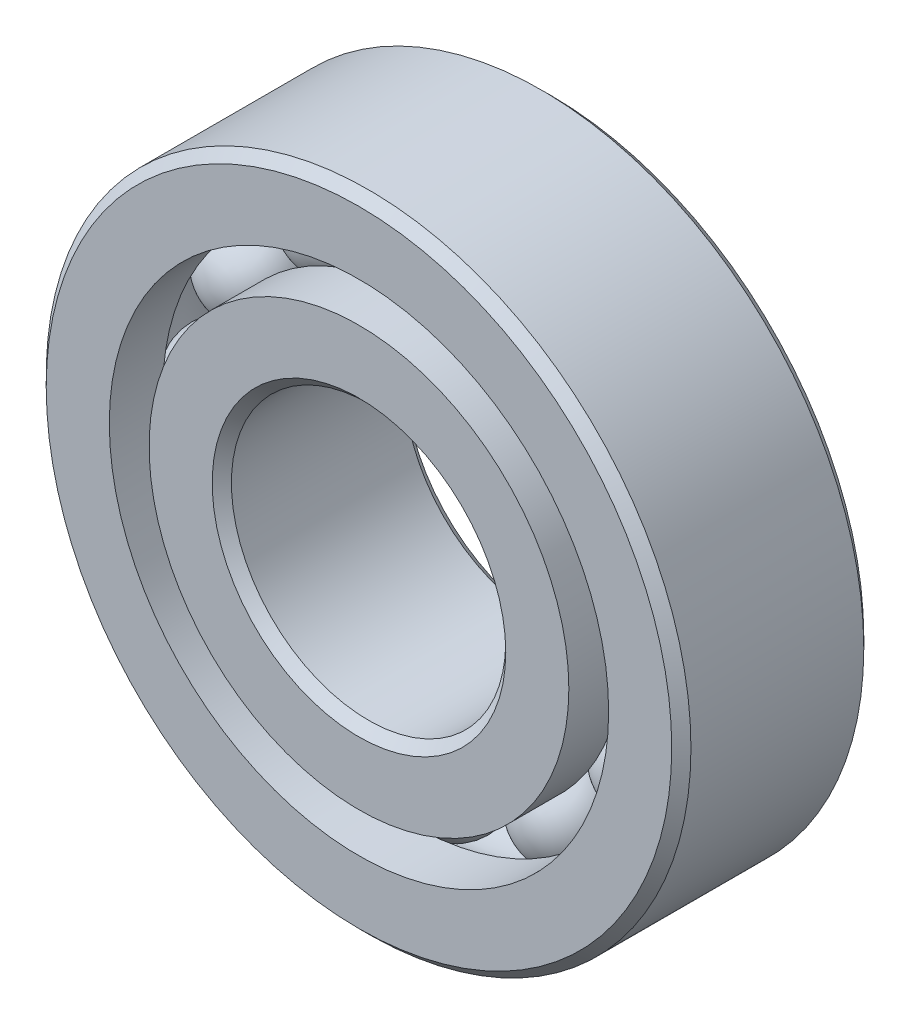
from build123d import *

# Parameters (mm, degrees)
CIRPATTERN1_COUNT = 12


with BuildPart() as part:
    # Sketch1 → Revolve1 (revolve)
    with BuildSketch(Plane(origin=(0, 0, 0), x_dir=(0, 0, -1), z_dir=(1, 0, 0))):
        with BuildLine():
            Line((6.3, 23.5), (-6.3, 23.5))
            Line((-6.3, 23.5), (-7, 22.8))
            Line((-7, 22.8), (-7, 18.200549451))
            Line((-7, 18.200549451), (-3.111111111, 18.200549451))
            ThreePointArc((-3.111111111, 18.200549451), (0, 20.182652918), (3.111111111, 18.200549451))
            Line((3.111111111, 18.200549451), (7, 18.200549451))
            Line((7, 18.200549451), (7, 22.8))
            Line((7, 22.8), (6.3, 23.5))
        make_face()
    revolve(axis=Axis((0, 0, 7), (0, 0, -1)))


with BuildPart() as body_2:
    # Sketch3 → Revolve3 (revolve)
    with BuildSketch(Plane(origin=(0, 0, 0), x_dir=(0, 0, -1), z_dir=(1, 0, 0))):
        with BuildLine():
            Line((-7, 15.299450549), (-3.111111111, 15.299450549))
            ThreePointArc((-3.111111111, 15.299450549), (0, 13.317347082), (3.111111111, 15.299450549))
            Line((3.111111111, 15.299450549), (7, 15.299450549))
            Line((7, 15.299450549), (7, 10.7))
            Line((7, 10.7), (6.3, 10))
            Line((6.3, 10), (-6.3, 10))
            Line((-6.3, 10), (-7, 10.7))
            Line((-7, 10.7), (-7, 15.299450549))
        make_face()
    revolve(axis=Axis((0, 0, 7), (0, 0, -1)))


with BuildPart() as body_3:
    # Sketch4 → Revolve4 (revolve)
    with BuildSketch(Plane(origin=(0, 0, 0), x_dir=(0, 0, -1), z_dir=(1, 0, 0))):
        with BuildLine():
            Line((-3.432652918, 16.75), (3.432652918, 16.75))
            ThreePointArc((3.432652918, 16.75), (0, 20.182652918), (-3.432652918, 16.75))
        make_face()
    revolve(axis=Axis((0, 16.75, 3.432652918), (0, 0, -1)))


with BuildPart() as cirpattern1_1:
    # CirPattern1: pattern copy
    add(body_3.part.rotate(Axis((0, 0, -7), (0, 0, 1)), 1 * 360 / CIRPATTERN1_COUNT))


with BuildPart() as cirpattern1_2:
    # CirPattern1: pattern copy
    add(body_3.part.rotate(Axis((0, 0, -7), (0, 0, 1)), 2 * 360 / CIRPATTERN1_COUNT))


with BuildPart() as cirpattern1_3:
    # CirPattern1: pattern copy
    add(body_3.part.rotate(Axis((0, 0, -7), (0, 0, 1)), 3 * 360 / CIRPATTERN1_COUNT))


with BuildPart() as cirpattern1_4:
    # CirPattern1: pattern copy
    add(body_3.part.rotate(Axis((0, 0, -7), (0, 0, 1)), 4 * 360 / CIRPATTERN1_COUNT))


with BuildPart() as cirpattern1_5:
    # CirPattern1: pattern copy
    add(body_3.part.rotate(Axis((0, 0, -7), (0, 0, 1)), 5 * 360 / CIRPATTERN1_COUNT))


with BuildPart() as cirpattern1_6:
    # CirPattern1: pattern copy
    add(body_3.part.rotate(Axis((0, 0, -7), (0, 0, 1)), 6 * 360 / CIRPATTERN1_COUNT))


with BuildPart() as cirpattern1_7:
    # CirPattern1: pattern copy
    add(body_3.part.rotate(Axis((0, 0, -7), (0, 0, 1)), 7 * 360 / CIRPATTERN1_COUNT))


with BuildPart() as cirpattern1_8:
    # CirPattern1: pattern copy
    add(body_3.part.rotate(Axis((0, 0, -7), (0, 0, 1)), 8 * 360 / CIRPATTERN1_COUNT))


with BuildPart() as cirpattern1_9:
    # CirPattern1: pattern copy
    add(body_3.part.rotate(Axis((0, 0, -7), (0, 0, 1)), 9 * 360 / CIRPATTERN1_COUNT))


with BuildPart() as cirpattern1_10:
    # CirPattern1: pattern copy
    add(body_3.part.rotate(Axis((0, 0, -7), (0, 0, 1)), 10 * 360 / CIRPATTERN1_COUNT))


with BuildPart() as cirpattern1_11:
    # CirPattern1: pattern copy
    add(body_3.part.rotate(Axis((0, 0, -7), (0, 0, 1)), 11 * 360 / CIRPATTERN1_COUNT))


solid = Compound([part.part, body_2.part, body_3.part, cirpattern1_1.part, cirpattern1_2.part, cirpattern1_3.part, cirpattern1_4.part, cirpattern1_5.part, cirpattern1_6.part, cirpattern1_7.part, cirpattern1_8.part, cirpattern1_9.part, cirpattern1_10.part, cirpattern1_11.part])
